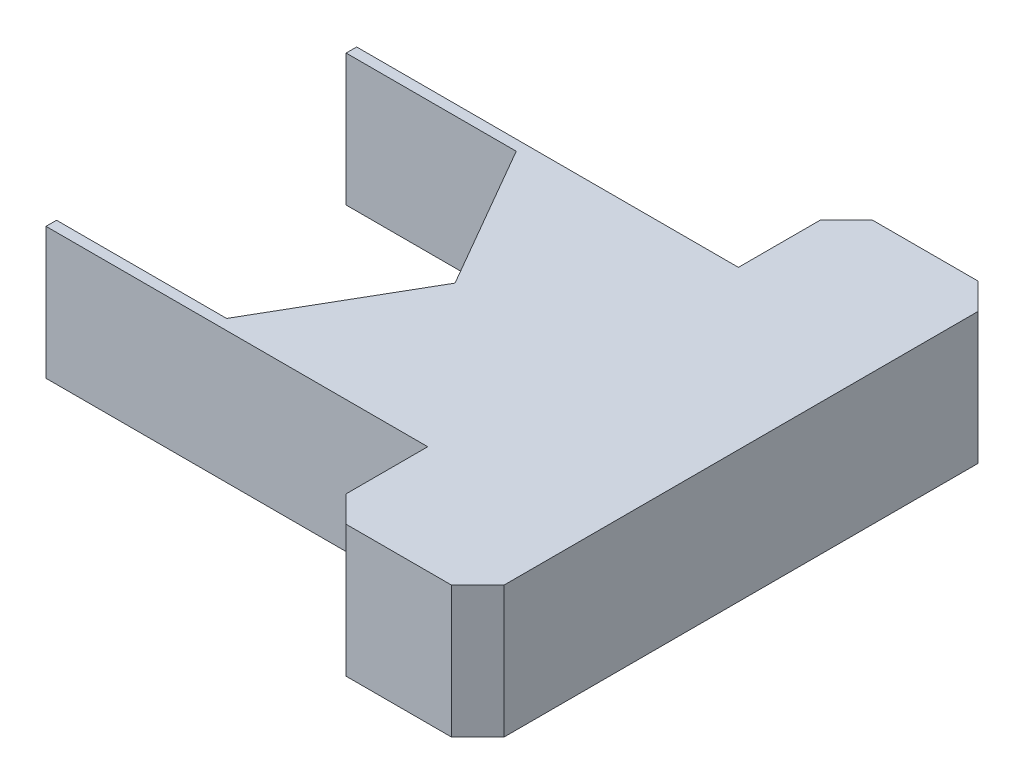
from build123d import *

# Parameters (mm, degrees)
BOSS_EXTRUDE1_DEPTH = 2.5
CHAMFER1_SIZE       = 0.5


with BuildPart() as part:
    # Sketch1 → Boss-Extrude1 (new body)
    with BuildSketch(Plane(origin=(0, 0, 0), x_dir=(1, 0, 0), z_dir=(0, 1, 0))):
        Polygon((1.662768775, 2.75), (3.250482016, 0), (1.662768775, -2.75), (-1.567505981, -2.75), (-1.567505981, -2.95), (5.682494019, -2.95), (5.682494019, 2.95), (-1.567505981, 2.95), (-1.567505981, 2.75), align=None)
        Polygon((5.682494019, 5), (5.682494019, 2.95), (5.682494019, -2.95), (5.682494019, -5), (8.682494019, -5), (8.682494019, 5), align=None)
    extrude(amount=BOSS_EXTRUDE1_DEPTH)

    # Chamfer1
    chamfer1_edges = [part.edges().sort_by_distance(p)[0] for p in [
        (5.682494019, 1.25, -5),
        (8.682494019, 1.25, -5),
        (8.682494019, 1.25, 5),
        (5.682494019, 1.25, 5),
    ]]
    chamfer(chamfer1_edges, length=CHAMFER1_SIZE)


solid = part.part
